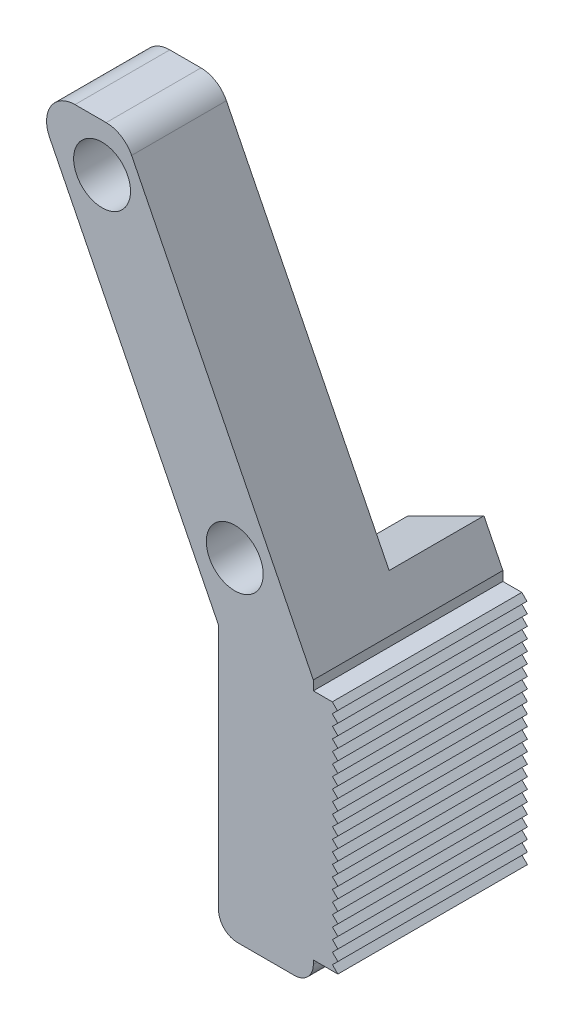
from build123d import *

# Parameters (mm, degrees)
SKETCH2_R           = 1.5
BOSS_EXTRUDE1_DEPTH = 10
SKETCH3_W           = 5
SKETCH3_H           = 22.360679775
CUT_EXTRUDE1_DEPTH  = 10
FILLET2_R           = 1.5
FILLET3_R           = 1
BOSS_EXTRUDE2_DEPTH = 10


with BuildPart() as part:
    # Sketch2 → Boss-Extrude1 (new body)
    with BuildSketch(Plane.XY):
        Polygon((0, 0), (10, -20), (10, -34), (15, -34), (15, -20), (5, 0), align=None)
        with Locations((3.855019194, -2.5)):
            Circle(SKETCH2_R, mode=Mode.SUBTRACT)
        with Locations((10.855019194, -16.5)):
            Circle(SKETCH2_R, mode=Mode.SUBTRACT)
    extrude(amount=BOSS_EXTRUDE1_DEPTH)

    # Sketch3 → Cut-Extrude1 (cut)
    with BuildSketch(Plane(origin=(0, 0, 0), x_dir=(0, 0, 1), z_dir=(-0.894427191, -0.447213595, 0))):
        with Locations((2.5, -11.180339888)):
            Rectangle(SKETCH3_W, SKETCH3_H)
    extrude(amount=-CUT_EXTRUDE1_DEPTH, mode=Mode.SUBTRACT)

    # Fillet2
    fillet2_edges = [part.edges().sort_by_distance(p)[0] for p in [
        (0, 0, 7.5),
        (5, 0, 7.5),
    ]]
    fillet(fillet2_edges, radius=FILLET2_R)

    # Fillet3
    fillet3_edges = [part.edges().sort_by_distance(p)[0] for p in [
        (15, -34, 5),
        (10, -34, 5),
    ]]
    fillet(fillet3_edges, radius=FILLET3_R)

    # Sketch4 → Boss-Extrude2 (add)
    with BuildSketch(Plane.XY.offset(10)):
        Polygon((15, -20.5), (16, -20.5), (16.271607252, -20.771607252), (16, -21.043214505), (16.290943636, -21.334158141), (16.008789905, -21.616311872), (16.295338588, -21.902860555), (16.008789905, -22.189409238), (16.295338588, -22.475957922), (16.008789905, -22.762506605), (16.295338588, -23.049055289), (16.008789905, -23.335603972), (16.295338588, -23.622152655), (16.008789905, -23.908701339), (16.295338588, -24.195250022), (16.008789905, -24.481798706), (16.295338588, -24.768347389), (16.008789905, -25.054896072), (16.295338588, -25.341444756), (16.008789905, -25.627993439), (16.295338588, -25.914542122), (16.008789905, -26.201090806), (16.295338588, -26.487639489), (16.008789905, -26.774188173), (16.295338588, -27.060736856), (16.008789905, -27.347285539), (16.295338588, -27.633834223), (16.008789905, -27.920382906), (16.295338588, -28.20693159), (16.008789905, -28.493480273), (16.295338588, -28.780028956), (16.008789905, -29.06657764), (16.295338588, -29.353126323), (16.008789905, -29.639675006), (16.295338588, -29.92622369), (16.008789905, -30.212772373), (16.295338588, -30.499321057), (16.008789905, -30.78586974), (16.295338588, -31.072418423), (16.008789905, -31.358967107), (16.295338588, -31.64551579), (16.008789905, -31.932064474), (16.295338588, -32.218613157), (16.008789905, -32.50516184), (16.295338588, -32.791710524), (15, -32.791710524), align=None)
    extrude(amount=-BOSS_EXTRUDE2_DEPTH)


solid = part.part
